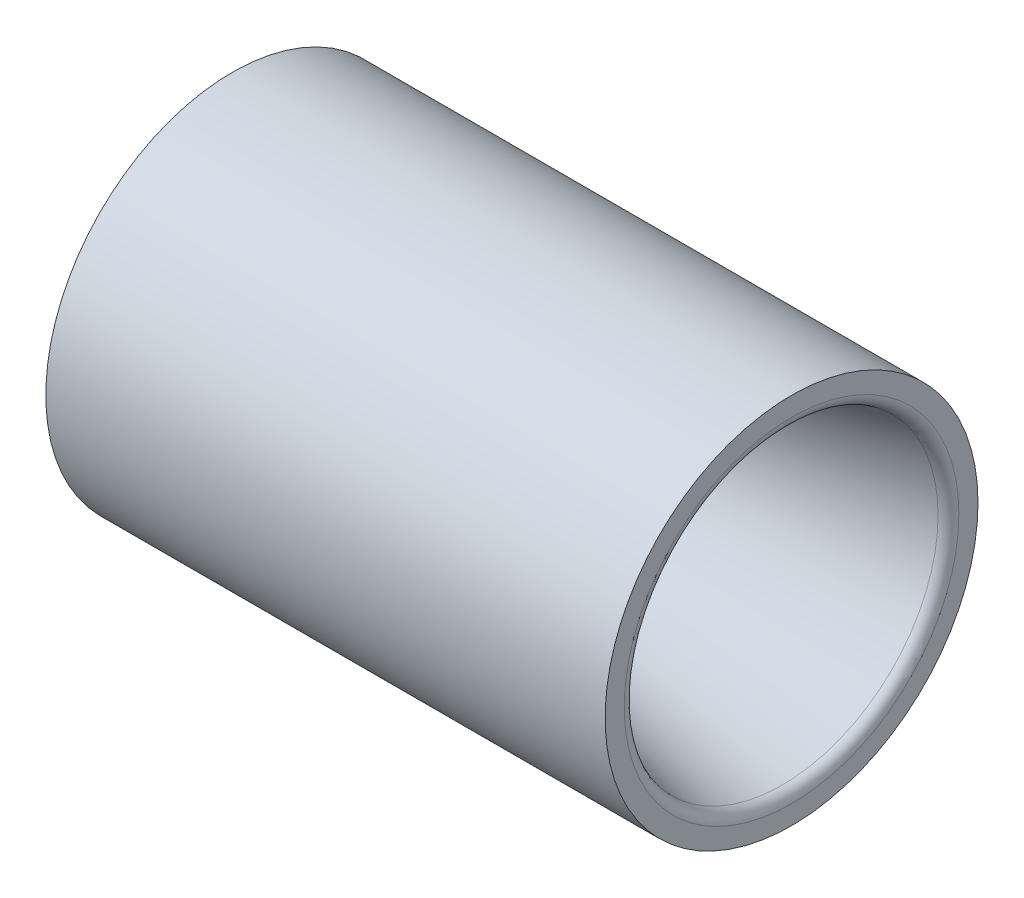
from build123d import *


with BuildPart() as part:
    # Sketch1 → Revolve1 (revolve)
    with BuildSketch(Plane(origin=(0, 0, 0), x_dir=(1, 0, 0), z_dir=(0, 1, 0))):
        with BuildLine():
            Line((-1.267499712, -21.231676029), (-49.062545314, -11.072525471))
            ThreePointArc((-49.062545314, -11.072525471), (-50.375512304, -10.864571929), (-51.703023788, -10.795))
            Line((-51.703023788, -10.795), (-63.5, -10.795))
            Line((-63.5, -10.795), (-63.5, -9.525))
            Line((-63.5, -9.525), (-76.2, -9.525))
            Line((-76.2, -9.525), (-76.2, -25.4))
            Line((-76.2, -25.4), (0, -25.4))
            Line((0, -25.4), (0, -22.796907819))
            ThreePointArc((0, -22.796907819), (-0.356611032, -21.78986933), (-1.267499712, -21.231676029))
        make_face()
    revolve(axis=Axis((3.175, 0, 0), (-1, 0, 0)))


solid = part.part
